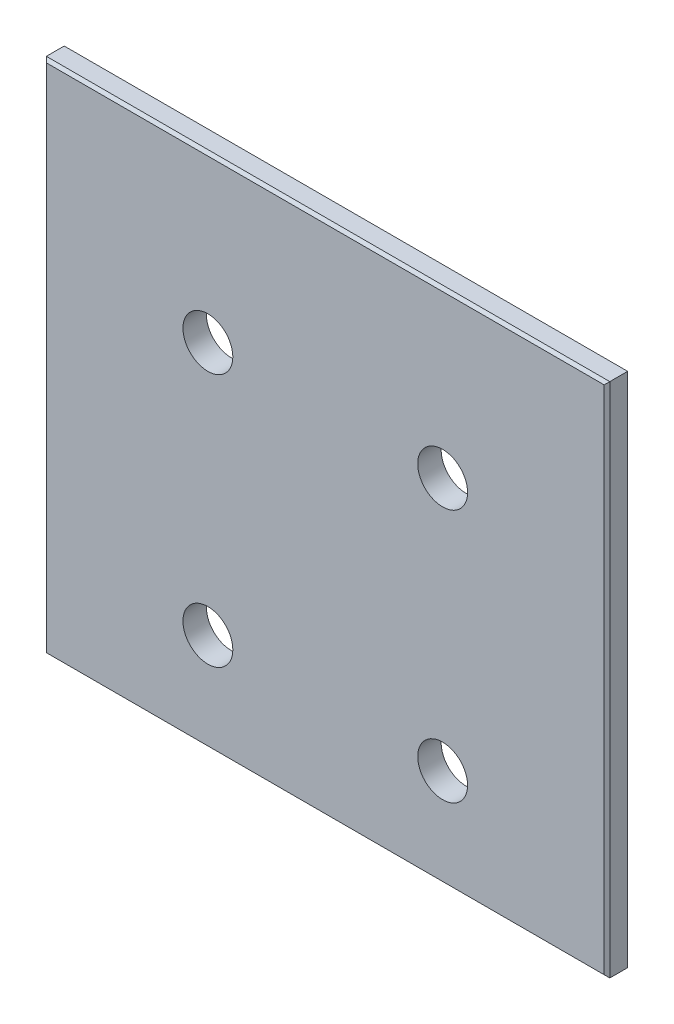
from build123d import *

# Parameters (mm, degrees)
SKETCH1_W               = 152.4
SKETCH1_H               = 139.7
EXTRUDE1_DEPTH          = 6.35
CHAMFER1_SIZE           = 0.762
F_1_2_CLEARANCE_HOLE1_D = 13.49248


with BuildPart() as part:
    # Sketch1 → Extrude1 (new body)
    with BuildSketch(Plane.XY):
        Rectangle(SKETCH1_W, SKETCH1_H)
    extrude(amount=EXTRUDE1_DEPTH)

    # Chamfer1
    chamfer1_edges = [part.edges().sort_by_distance(p)[0] for p in [
        (76.2, 0, 6.35),
        (0, 69.85, 6.35),
        (-76.2, 0, 6.35),
        (0, 69.85, 0),
        (76.2, 0, 0),
        (0, -69.85, 0),
        (-76.2, 0, 0),
        (0, -69.85, 6.35),
    ]]
    chamfer(chamfer1_edges, length=CHAMFER1_SIZE)

    # 1/2 Clearance Hole1 (through all)
    with Locations(Plane.XY.offset(6.35)):
        with Locations((-31.75, 25.4), (31.75, 25.4), (-31.75, -43.18), (31.75, -43.18)):
            Hole(F_1_2_CLEARANCE_HOLE1_D / 2)


solid = part.part
